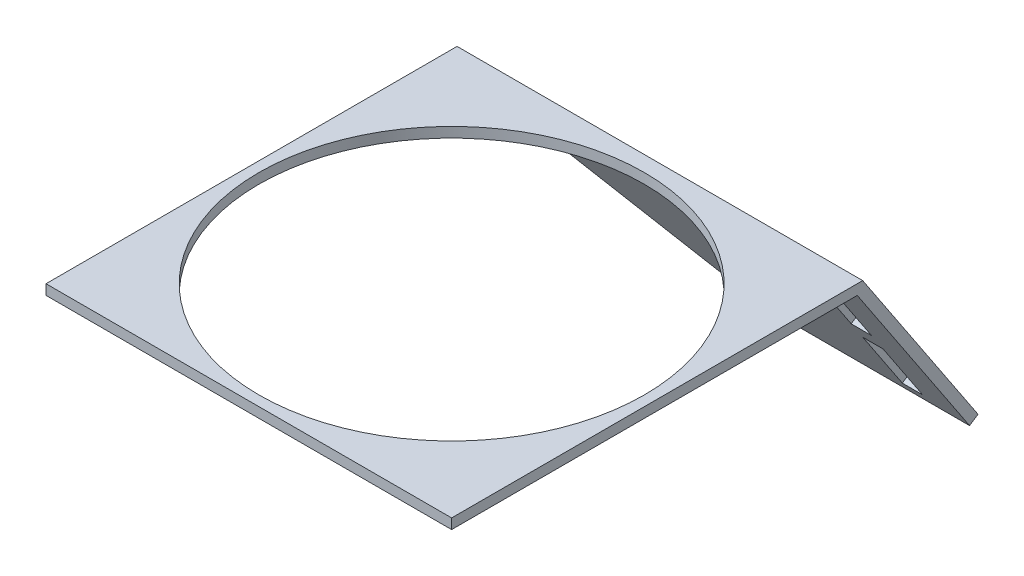
from build123d import *

# Parameters (mm, degrees)
SKETCH1_W           = 40
SKETCH1_H           = 40
SKETCH1_R           = 19
BOSS_EXTRUDE1_DEPTH = 1
BOSS_EXTRUDE3_DEPTH = 40
CUT_EXTRUDE1_DEPTH  = 40
SKETCH4_W           = 2
SKETCH4_H           = 17.959199538
CUT_EXTRUDE2_DEPTH  = 40
SKETCH5_W           = 4.291289536
SKETCH5_H           = 2.060082618
BOSS_EXTRUDE4_DEPTH = 1


with BuildPart() as part:
    # Sketch1 → Boss-Extrude1 (new body)
    with BuildSketch(Plane(origin=(0, 0, 0), x_dir=(1, 0, 0), z_dir=(0, 1, 0))):
        with Locations((-20, -4.822405003)):
            Rectangle(SKETCH1_W, SKETCH1_H)
        with Locations((-20, -4.822405003)):
            Circle(SKETCH1_R, mode=Mode.SUBTRACT)
    extrude(amount=BOSS_EXTRUDE1_DEPTH)

    # Sketch2 → Boss-Extrude3 (add)
    with BuildSketch(Plane(origin=(0, 0, 0), x_dir=(0, 0, -1), z_dir=(1, 0, 0))):
        Polygon((15.177594997, 0), (26.251567878, -16.654342515), (27.084285004, -16.100643871), (15.713552938, 1), (15.177594997, 1), align=None)
    extrude(amount=-BOSS_EXTRUDE3_DEPTH)

    # Sketch3 → Cut-Extrude1 (cut)
    with BuildSketch(Plane(origin=(0, 6.997999648, -10.524414707), x_dir=(1, 0, 0), z_dir=(0, -0.553698644, 0.832717126))):
        Polygon((-20, -28.40381377), (-40, -8.40381377), (-40, -28.40381377), align=None)
    extrude(amount=-CUT_EXTRUDE1_DEPTH, mode=Mode.SUBTRACT)

    # Sketch4 → Cut-Extrude2 (cut)
    with BuildSketch(Plane(origin=(0, 6.997999648, -10.524414707), x_dir=(1, 0, 0), z_dir=(0, -0.553698644, 0.832717126))):
        with Locations((-5, -18.291545123)):
            Rectangle(SKETCH4_W, SKETCH4_H)
    extrude(amount=-CUT_EXTRUDE2_DEPTH, mode=Mode.SUBTRACT)

    # Sketch5 → Boss-Extrude4 (add)
    with BuildSketch(Plane(origin=(0, 6.997999648, -10.524414707), x_dir=(1, 0, 0), z_dir=(0, -0.553698644, 0.832717126))):
        with Locations((-5.191272024, -19.192802864)):
            Rectangle(SKETCH5_W, SKETCH5_H)
    extrude(amount=-BOSS_EXTRUDE4_DEPTH)


solid = part.part
